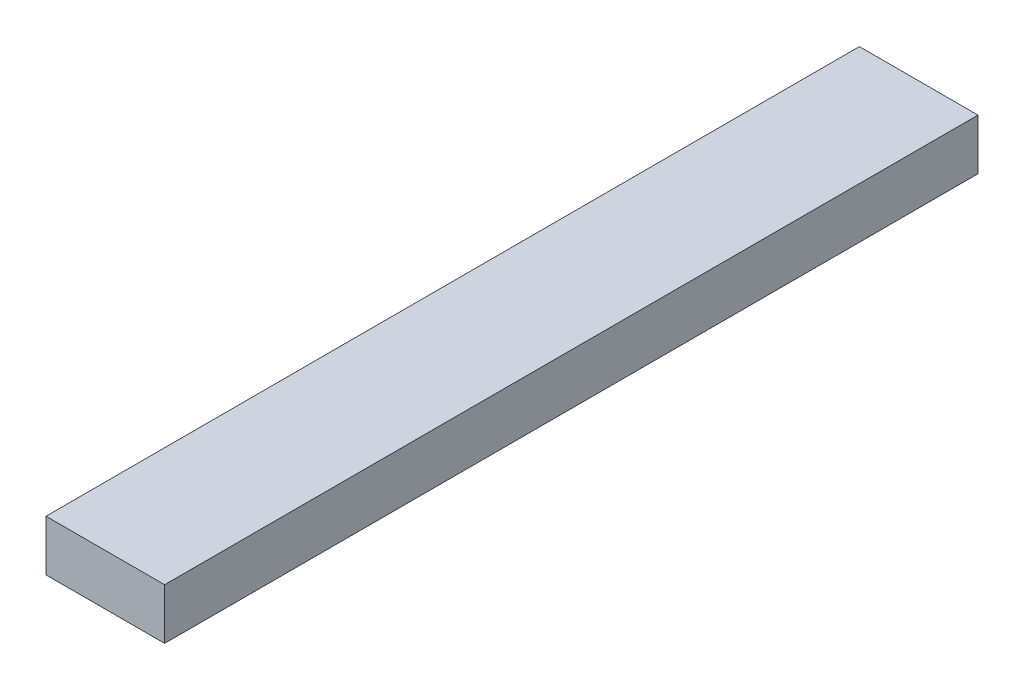
from build123d import *

# Parameters (mm, degrees)
SKETCH2_W           = 88.9
SKETCH2_H           = 38.1
BOSS_EXTRUDE1_DEPTH = 609.6


with BuildPart() as part:
    # Sketch2 → Boss-Extrude1 (new body)
    with BuildSketch(Plane.XY):
        with Locations((-44.45, 54.5274942)):
            Rectangle(SKETCH2_W, SKETCH2_H)
    extrude(amount=BOSS_EXTRUDE1_DEPTH)


solid = part.part
